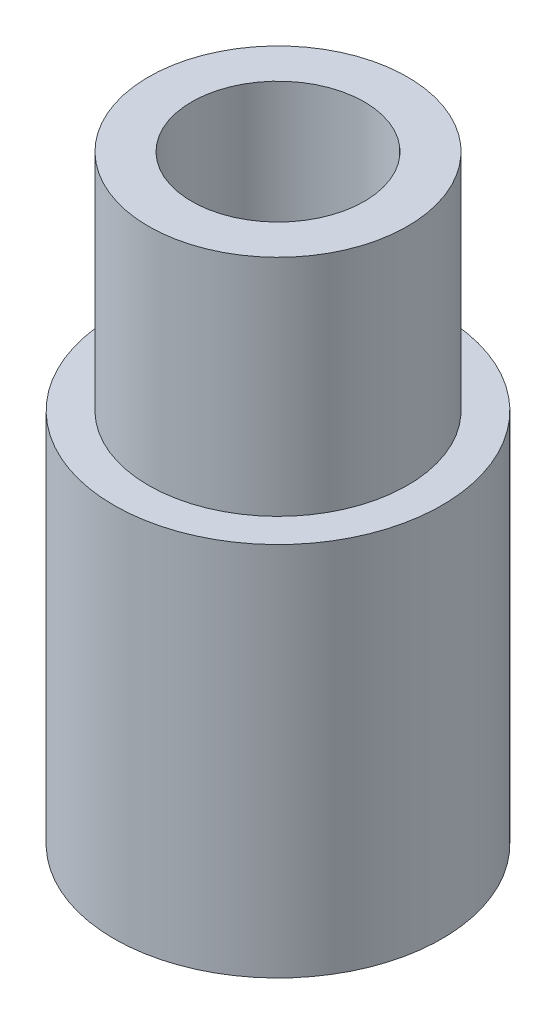
from build123d import *

# Parameters (mm, degrees)
SKETCH1_R           = 1.9
BOSS_EXTRUDE1_DEPTH = 6.95
SKETCH2_OUTSIDE_W   = 7.558
SKETCH2_OUTSIDE_H   = 7.558
SKETCH2_OUTSIDE_R   = 1.5
CUT_EXTRUDE1_DEPTH  = 2.6
SKETCH3_R           = 1
CUT_EXTRUDE2_DEPTH  = 7.95


with BuildPart() as part:
    # Sketch1 → Boss-Extrude1 (new body)
    with BuildSketch(Plane(origin=(0, 0, 0), x_dir=(1, 0, 0), z_dir=(0, 1, 0))):
        Circle(SKETCH1_R)
    extrude(amount=BOSS_EXTRUDE1_DEPTH)

    # Sketch2 outside → Cut-Extrude1 (cut)
    with BuildSketch(Plane(origin=(0, 6.95, 0), x_dir=(1, 0, 0), z_dir=(0, 1, 0))):
        Rectangle(SKETCH2_OUTSIDE_W, SKETCH2_OUTSIDE_H)
        Circle(SKETCH2_OUTSIDE_R, mode=Mode.SUBTRACT)
    extrude(amount=-CUT_EXTRUDE1_DEPTH, mode=Mode.SUBTRACT)

    # Sketch3 → Cut-Extrude2 (cut, through all)
    with BuildSketch(Plane.XZ):
        Circle(SKETCH3_R)
    extrude(amount=-CUT_EXTRUDE2_DEPTH, mode=Mode.SUBTRACT)


solid = part.part
